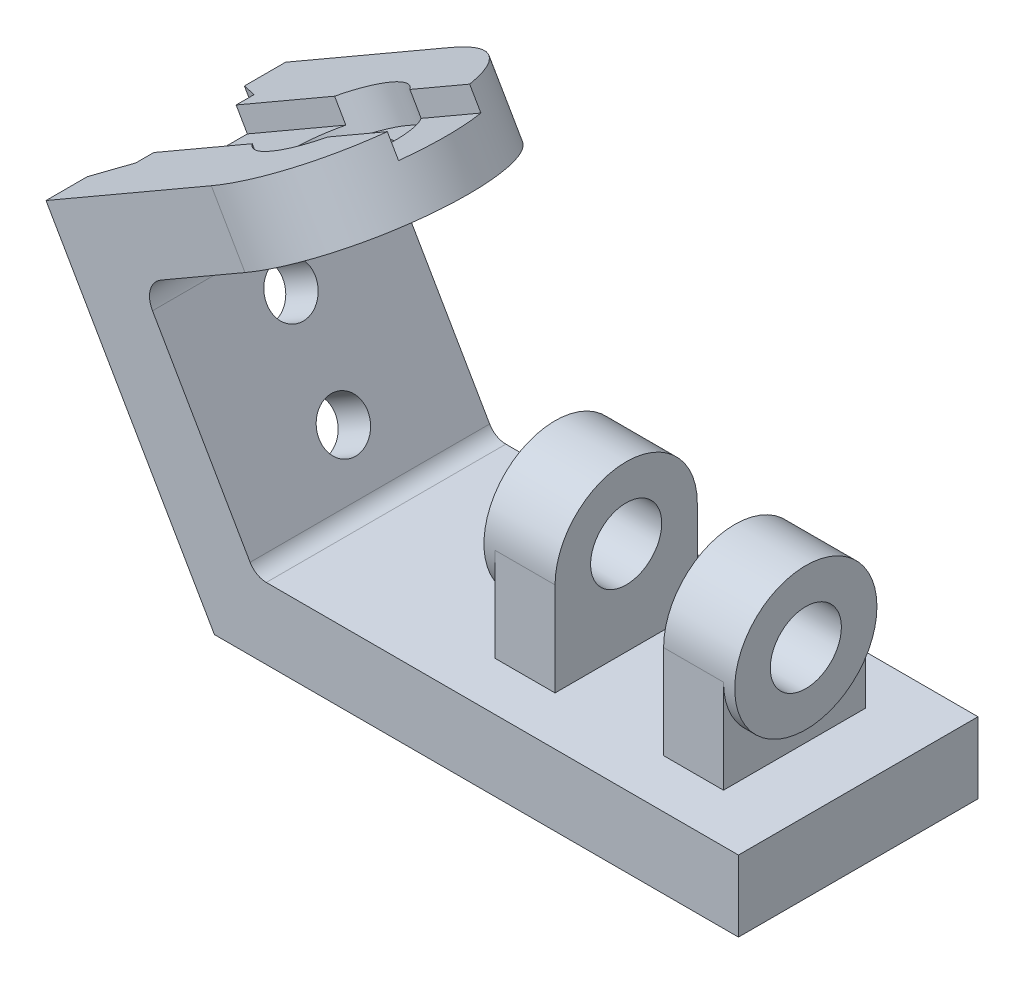
from build123d import *

# Parameters (mm, degrees)
BOSS_EXTRUDE1_DEPTH = 64
SKETCH2_R           = 9.5
BOSS_EXTRUDE3_DEPTH = 18
CUT_EXTRUDE1_DEPTH  = 128
SKETCH4_W           = 79.210461268
SKETCH4_H           = 22
CUT_EXTRUDE2_DEPTH  = 6
SKETCH5_R           = 16
CUT_EXTRUDE4_DEPTH  = 9
SKETCH6_R           = 6.5
CUT_EXTRUDE6_DEPTH  = 10
FILLET1_R           = 5
FILLET2_R           = 6
SKETCH7_W           = 16
SKETCH7_H           = 38
BOSS_EXTRUDE4_DEPTH = 25
SKETCH8_R           = 19
SKETCH8_R_2         = 9.5
BOSS_EXTRUDE5_DEPTH = 19
SKETCH9_R           = 9.5
CUT_EXTRUDE7_DEPTH  = 19
SKETCH11_R          = 9.5
CUT_EXTRUDE8_DEPTH  = 19


with BuildPart() as part:
    # Sketch1 → Boss-Extrude1 (new body)
    with BuildSketch(Plane.XY):
        Polygon((-70, -9.5), (-115, 68.442286341), (-98.545517328, 77.942286341), (-59.030344885, 9.5), (70, 9.5), (70, -9.5), align=None)
    extrude(amount=BOSS_EXTRUDE1_DEPTH)

    # Sketch2 → Boss-Extrude3 (add)
    with BuildSketch(Plane(origin=(-58.386379332, 101.128175473, 0), x_dir=(0.866025404, 0.5, 0), z_dir=(-0.5, 0.866025404, 0))):
        with BuildLine():
            Line((-46.371778265, 0), (-46.371778265, -64))
            Line((-46.371778265, -64), (-14.371778265, -64))
            ThreePointArc((-14.371778265, -64), (17.628221735, -32), (-14.371778265, 0))
            Line((-14.371778265, 0), (-46.371778265, 0))
        make_face()
        with Locations((-14.371778265, -32)):
            Circle(SKETCH2_R, mode=Mode.SUBTRACT)
    extrude(amount=-BOSS_EXTRUDE3_DEPTH)

    # Sketch3 → Cut-Extrude1 (cut)
    with BuildSketch(Plane(origin=(-58.386379332, 101.128175473, 0), x_dir=(0.866025404, 0.5, 0), z_dir=(-0.5, 0.866025404, 0))):
        Polygon((-56.371778265, -16.196152423), (-56.371778265, -47.803847577), (-65.371778265, -53), (-65.371778265, -11), align=None)
    extrude(amount=-CUT_EXTRUDE1_DEPTH, mode=Mode.SUBTRACT)

    # Sketch4 → Cut-Extrude2 (cut)
    with BuildSketch(Plane(origin=(-58.386379332, 101.128175473, 0), x_dir=(0.866025404, 0.5, 0), z_dir=(-0.5, 0.866025404, 0))):
        with Locations((-20.439118131, -32)):
            Rectangle(SKETCH4_W, SKETCH4_H)
    extrude(amount=-CUT_EXTRUDE2_DEPTH, mode=Mode.SUBTRACT)

    # Sketch5 → Cut-Extrude4 (cut)
    with BuildSketch(Plane(origin=(-58.386379332, 101.128175473, 0), x_dir=(0.866025404, 0.5, 0), z_dir=(-0.5, 0.866025404, 0))):
        with Locations((-14.371778265, -32)):
            Circle(SKETCH5_R)
    extrude(amount=-CUT_EXTRUDE4_DEPTH, mode=Mode.SUBTRACT)

    # Sketch6 → Cut-Extrude6 (cut)
    with BuildSketch(Plane(origin=(-48.819392034, -28.185889132, 0), x_dir=(0, 0, 1), z_dir=(-0.866025404, -0.5, 0))):
        with Locations((32, 82.772758664)):
            Circle(SKETCH6_R)
        with Locations((32, 54.772758664)):
            Circle(SKETCH6_R)
    extrude(amount=-CUT_EXTRUDE6_DEPTH, mode=Mode.SUBTRACT)

    # Fillet1
    fillet1_edges = [part.edges().sort_by_distance(p)[0] for p in [
        (-59.030344885, 9.5, 32),
    ]]
    fillet(fillet1_edges, radius=FILLET1_R)

    # Fillet2
    fillet2_edges = [part.edges().sort_by_distance(p)[0] for p in [
        (-89.545517328, 62.353829072, 32),
    ]]
    fillet(fillet2_edges, radius=FILLET2_R)

    # Sketch7 → Boss-Extrude4 (add)
    with BuildSketch(Plane(origin=(0, 9.5, 0), x_dir=(1, 0, 0), z_dir=(0, 1, 0))):
        with Locations((45, -32)):
            Rectangle(SKETCH7_W, SKETCH7_H)
    boss_extrude4 = extrude(amount=BOSS_EXTRUDE4_DEPTH)

    # Sketch8 → Boss-Extrude5 (add)
    with BuildSketch(Plane(origin=(56, 0, 0), x_dir=(0, 0, -1), z_dir=(1, 0, 0))):
        with Locations((-32, 34.5)):
            Circle(SKETCH8_R)
        with Locations((-32, 34.5)):
            Circle(SKETCH8_R_2, mode=Mode.SUBTRACT)
    boss_extrude5 = extrude(amount=-BOSS_EXTRUDE5_DEPTH)

    # Sketch9 → Cut-Extrude7 (cut)
    with BuildSketch(Plane(origin=(56, 0, 0), x_dir=(0, 0, -1), z_dir=(1, 0, 0))):
        with Locations((-32, 34.5)):
            Circle(SKETCH9_R)
    extrude(amount=-CUT_EXTRUDE7_DEPTH, mode=Mode.SUBTRACT)

    # Mirror1: Boss-Extrude4, Boss-Extrude5 across plane
    add(boss_extrude4.mirror(Plane(origin=(22.5, 0, 0), x_dir=(0, 0, 1), z_dir=(1, 0, 0))))
    add(boss_extrude5.mirror(Plane(origin=(22.5, 0, 0), x_dir=(0, 0, 1), z_dir=(1, 0, 0))))

    # Sketch11 → Cut-Extrude8 (cut)
    with BuildSketch(Plane.ZY.offset(11)):
        with Locations((32, 34.5)):
            Circle(SKETCH11_R)
    extrude(amount=-CUT_EXTRUDE8_DEPTH, mode=Mode.SUBTRACT)


solid = part.part
